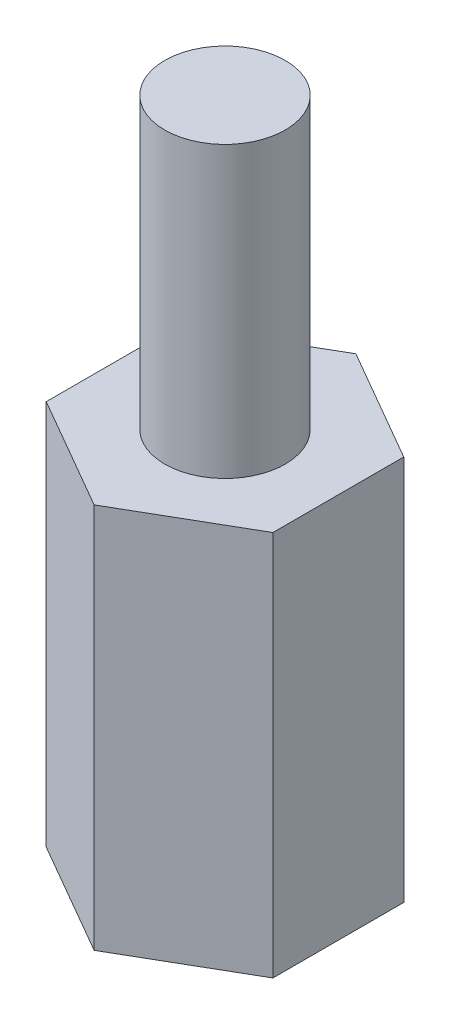
from build123d import *

# Parameters (mm, degrees)
BOSS_EXTRUDE1_DEPTH = 8
SKETCH2_R           = 1.25
BOSS_EXTRUDE2_DEPTH = 6
CUT_EXTRUDE1_START  = -8
SKETCH2_2_R         = 1.25
CUT_EXTRUDE1_DEPTH  = 6


with BuildPart() as part:
    # Sketch1 → Boss-Extrude1 (new body)
    with BuildSketch(Plane(origin=(0, 0, 0), x_dir=(1, 0, 0), z_dir=(0, 1, 0))):
        Polygon((0, 2.713546265), (-2.35, 1.356773133), (-2.35, -1.356773133), (0, -2.713546265), (2.35, -1.356773133), (2.35, 1.356773133), align=None)
    extrude(amount=BOSS_EXTRUDE1_DEPTH)

    # Sketch2 → Boss-Extrude2 (add)
    with BuildSketch(Plane(origin=(0, 8, 0), x_dir=(1, 0, 0), z_dir=(0, 1, 0))):
        Circle(SKETCH2_R)
    extrude(amount=BOSS_EXTRUDE2_DEPTH)

    # Sketch2_2 → Cut-Extrude1 (cut)
    with BuildSketch(Plane(origin=(0, 8, 0), x_dir=(1, 0, 0), z_dir=(0, 1, 0)).offset(CUT_EXTRUDE1_START)):
        Circle(SKETCH2_2_R)
    extrude(amount=CUT_EXTRUDE1_DEPTH, mode=Mode.SUBTRACT)


solid = part.part
